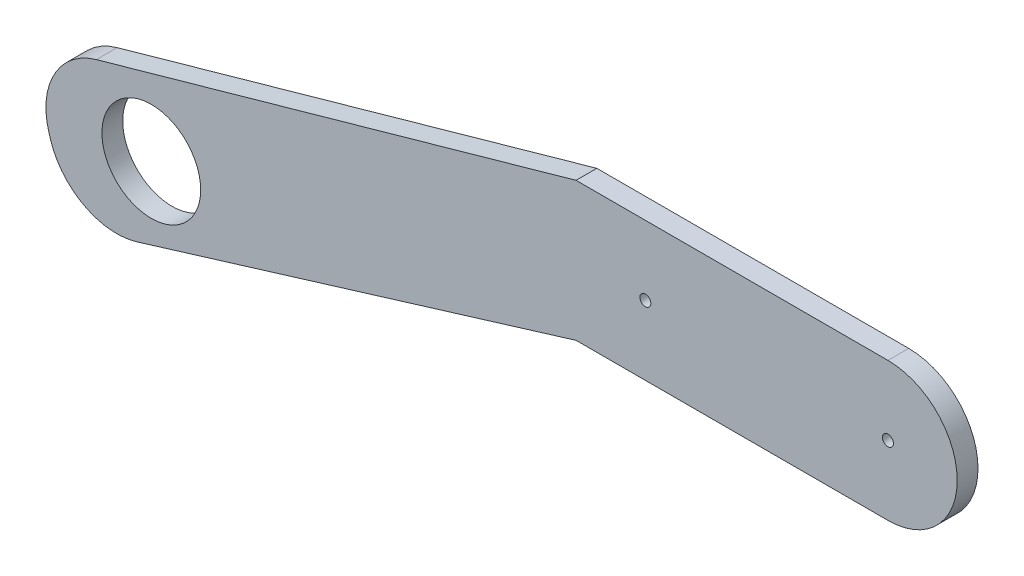
from build123d import *

# Parameters (mm, degrees)
CROQUIS1_R              = 14.25
CROQUIS1_R_2            = 1.58
SALIENTE_EXTRUIR1_DEPTH = 6


with BuildPart() as part:
    # Croquis1 → Saliente-Extruir1 (new body)
    with BuildSketch(Plane.XY):
        with BuildLine():
            Line((110.034775737, 174.96231782), (-28.386947122, 135.91609695))
            ThreePointArc((-28.386947122, 135.91609695), (-40.514665945, 126.246932811), (-42.085274513, 110.816200885))
            Line((-42.085274513, 110.816200885), (-41.681314374, 109.494906807))
            ThreePointArc((-41.681314374, 109.494906807), (-31.943245693, 97.681684863), (-16.704181948, 96.21432992))
            Line((-16.704181948, 96.21432992), (110.034775737, 134.96231782))
            Line((110.034775737, 134.96231782), (200.034775737, 134.96231782))
            ThreePointArc((200.034775737, 134.96231782), (220.034775737, 154.96231782), (200.034775737, 174.96231782))
            Line((200.034775737, 174.96231782), (110.034775737, 174.96231782))
        make_face()
        with Locations((-12.544553236, 118.39989117)):
            Circle(CROQUIS1_R, mode=Mode.SUBTRACT)
        with Locations((200.034775737, 154.96231782)):
            Circle(CROQUIS1_R_2, mode=Mode.SUBTRACT)
        with Locations((130.034775737, 154.96231782)):
            Circle(CROQUIS1_R_2, mode=Mode.SUBTRACT)
    extrude(amount=SALIENTE_EXTRUIR1_DEPTH)


solid = part.part
